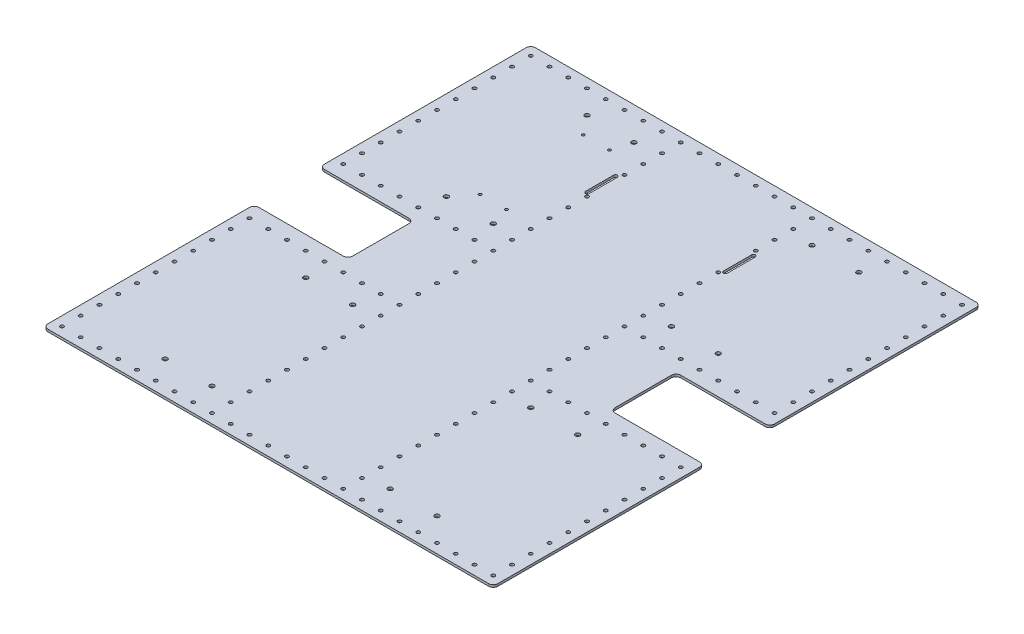
from build123d import *

# Parameters (mm, degrees)
BOSS_EXTRUDE1_DEPTH = 3.175
SKETCH2_R           = 2.4
CUT_EXTRUDE1_DEPTH  = 119.634
SKETCH3_R           = 2.425
CUT_EXTRUDE2_DEPTH  = 899.749353616
SKETCH3_3_R         = 2.425
CUT_EXTRUDE3_DEPTH  = 899.749353616
SKETCH4_R           = 3.100000023
SKETCH4_R_2         = 3.093357666
CUT_EXTRUDE4_DEPTH  = 899.749353616
FILLET1_R           = 6.35
SKETCH5_R           = 1.905
CUT_EXTRUDE5_DEPTH  = 899.749353616
CUT_EXTRUDE6_DEPTH  = 899.749353616
BOSS_EXTRUDE2_DEPTH = 3.175


with BuildPart() as part:
    # Sketch1 → Boss-Extrude1 (new body)
    with BuildSketch(Plane(origin=(0, 0, 0), x_dir=(1, 0, 0), z_dir=(0, 1, 0))):
        Polygon((609.6, 0), (0, 0), (0, -285.75), (127, -285.75), (127, -374.65), (0, -374.65), (0, -660.4), (609.6, -660.4), (609.6, -374.65), (482.6, -374.65), (482.6, -285.75), (609.6, -285.75), align=None)
    extrude(amount=BOSS_EXTRUDE1_DEPTH)

    # Sketch2 → Cut-Extrude1 (cut)
    with BuildSketch(Plane(origin=(0, 3.175, 0), x_dir=(1, 0, 0), z_dir=(0, 1, 0))):
        with Locations((12.7, -647.7)):
            Circle(SKETCH2_R)
        with Locations((38.1, -647.7)):
            Circle(SKETCH2_R)
        with Locations((63.5, -647.7)):
            Circle(SKETCH2_R)
        with Locations((88.9, -647.7)):
            Circle(SKETCH2_R)
        with Locations((114.3, -647.7)):
            Circle(SKETCH2_R)
        with Locations((139.7, -647.7)):
            Circle(SKETCH2_R)
        with Locations((165.1, -647.7)):
            Circle(SKETCH2_R)
        with Locations((190.5, -647.7)):
            Circle(SKETCH2_R)
        with Locations((215.9, -647.7)):
            Circle(SKETCH2_R)
        with Locations((241.3, -647.7)):
            Circle(SKETCH2_R)
        with Locations((266.7, -647.7)):
            Circle(SKETCH2_R)
        with Locations((292.1, -647.7)):
            Circle(SKETCH2_R)
        with Locations((317.5, -647.7)):
            Circle(SKETCH2_R)
        with Locations((342.9, -647.7)):
            Circle(SKETCH2_R)
        with Locations((368.3, -647.7)):
            Circle(SKETCH2_R)
        with Locations((393.7, -647.7)):
            Circle(SKETCH2_R)
        with Locations((419.1, -647.7)):
            Circle(SKETCH2_R)
        with Locations((444.5, -647.7)):
            Circle(SKETCH2_R)
        with Locations((469.9, -647.7)):
            Circle(SKETCH2_R)
        with Locations((495.3, -647.7)):
            Circle(SKETCH2_R)
        with Locations((520.7, -647.7)):
            Circle(SKETCH2_R)
        with Locations((546.1, -647.7)):
            Circle(SKETCH2_R)
        with Locations((571.5, -647.7)):
            Circle(SKETCH2_R)
        with Locations((596.9, -647.7)):
            Circle(SKETCH2_R)
        with Locations((12.7, -622.3)):
            Circle(SKETCH2_R)
        with Locations((12.7, -596.9)):
            Circle(SKETCH2_R)
        with Locations((12.7, -571.5)):
            Circle(SKETCH2_R)
        with Locations((12.7, -546.1)):
            Circle(SKETCH2_R)
        with Locations((12.7, -520.7)):
            Circle(SKETCH2_R)
        with Locations((12.7, -495.3)):
            Circle(SKETCH2_R)
        with Locations((12.7, -469.9)):
            Circle(SKETCH2_R)
        with Locations((12.7, -444.5)):
            Circle(SKETCH2_R)
        with Locations((12.7, -419.1)):
            Circle(SKETCH2_R)
        with Locations((12.7, -393.7)):
            Circle(SKETCH2_R)
        with Locations((596.9, -622.3)):
            Circle(SKETCH2_R)
        with Locations((596.9, -596.9)):
            Circle(SKETCH2_R)
        with Locations((596.9, -571.5)):
            Circle(SKETCH2_R)
        with Locations((596.9, -546.1)):
            Circle(SKETCH2_R)
        with Locations((596.9, -520.7)):
            Circle(SKETCH2_R)
        with Locations((596.9, -495.3)):
            Circle(SKETCH2_R)
        with Locations((596.9, -469.9)):
            Circle(SKETCH2_R)
        with Locations((596.9, -444.5)):
            Circle(SKETCH2_R)
        with Locations((596.9, -419.1)):
            Circle(SKETCH2_R)
        with Locations((596.9, -393.7)):
            Circle(SKETCH2_R)
        with Locations((215.9, -622.3)):
            Circle(SKETCH2_R)
        with Locations((393.7, -622.3)):
            Circle(SKETCH2_R)
        with Locations((215.9, -596.9)):
            Circle(SKETCH2_R)
        with Locations((393.7, -596.9)):
            Circle(SKETCH2_R)
        with Locations((215.9, -571.5)):
            Circle(SKETCH2_R)
        with Locations((393.7, -571.5)):
            Circle(SKETCH2_R)
        with Locations((215.9, -546.1)):
            Circle(SKETCH2_R)
        with Locations((393.7, -546.1)):
            Circle(SKETCH2_R)
        with Locations((215.9, -520.7)):
            Circle(SKETCH2_R)
        with Locations((393.7, -520.7)):
            Circle(SKETCH2_R)
        with Locations((215.9, -495.3)):
            Circle(SKETCH2_R)
        with Locations((393.7, -495.3)):
            Circle(SKETCH2_R)
        with Locations((215.9, -469.9)):
            Circle(SKETCH2_R)
        with Locations((393.7, -469.9)):
            Circle(SKETCH2_R)
        with Locations((215.9, -444.5)):
            Circle(SKETCH2_R)
        with Locations((393.7, -444.5)):
            Circle(SKETCH2_R)
        with Locations((215.9, -419.1)):
            Circle(SKETCH2_R)
        with Locations((393.7, -419.1)):
            Circle(SKETCH2_R)
        with Locations((215.9, -393.7)):
            Circle(SKETCH2_R)
        with Locations((393.7, -393.7)):
            Circle(SKETCH2_R)
        with Locations((215.9, -368.3)):
            Circle(SKETCH2_R)
        with Locations((393.7, -368.3)):
            Circle(SKETCH2_R)
        with Locations((215.9, -342.9)):
            Circle(SKETCH2_R)
        with Locations((393.7, -342.9)):
            Circle(SKETCH2_R)
        with Locations((215.9, -317.5)):
            Circle(SKETCH2_R)
        with Locations((393.7, -317.5)):
            Circle(SKETCH2_R)
        with Locations((215.9, -292.1)):
            Circle(SKETCH2_R)
        with Locations((393.7, -292.1)):
            Circle(SKETCH2_R)
        with Locations((215.9, -266.7)):
            Circle(SKETCH2_R)
        with Locations((393.7, -266.7)):
            Circle(SKETCH2_R)
        with Locations((215.9, -241.3)):
            Circle(SKETCH2_R)
        with Locations((393.7, -241.3)):
            Circle(SKETCH2_R)
        with Locations((215.9, -215.9)):
            Circle(SKETCH2_R)
        with Locations((393.7, -215.9)):
            Circle(SKETCH2_R)
        with Locations((215.9, -190.5)):
            Circle(SKETCH2_R)
        with Locations((393.7, -190.5)):
            Circle(SKETCH2_R)
        with Locations((215.9, -165.1)):
            Circle(SKETCH2_R)
        with Locations((393.7, -165.1)):
            Circle(SKETCH2_R)
        with Locations((215.9, -139.7)):
            Circle(SKETCH2_R)
        with Locations((393.7, -139.7)):
            Circle(SKETCH2_R)
        with Locations((215.9, -114.3)):
            Circle(SKETCH2_R)
        with Locations((393.7, -114.3)):
            Circle(SKETCH2_R)
        with Locations((215.9, -88.9)):
            Circle(SKETCH2_R)
        with Locations((393.7, -88.9)):
            Circle(SKETCH2_R)
        with Locations((215.9, -63.5)):
            Circle(SKETCH2_R)
        with Locations((393.7, -63.5)):
            Circle(SKETCH2_R)
        with Locations((215.9, -38.1)):
            Circle(SKETCH2_R)
        with Locations((393.7, -38.1)):
            Circle(SKETCH2_R)
        with Locations((215.9, -12.7)):
            Circle(SKETCH2_R)
        with Locations((393.7, -12.7)):
            Circle(SKETCH2_R)
        with Locations((12.7, -12.7)):
            Circle(SKETCH2_R)
        with Locations((38.1, -12.7)):
            Circle(SKETCH2_R)
        with Locations((63.5, -12.7)):
            Circle(SKETCH2_R)
        with Locations((88.9, -12.7)):
            Circle(SKETCH2_R)
        with Locations((114.3, -12.7)):
            Circle(SKETCH2_R)
        with Locations((139.7, -12.7)):
            Circle(SKETCH2_R)
        with Locations((165.1, -12.7)):
            Circle(SKETCH2_R)
        with Locations((190.5, -12.7)):
            Circle(SKETCH2_R)
        with Locations((241.3, -12.7)):
            Circle(SKETCH2_R)
        with Locations((266.7, -12.7)):
            Circle(SKETCH2_R)
        with Locations((292.1, -12.7)):
            Circle(SKETCH2_R)
        with Locations((317.5, -12.7)):
            Circle(SKETCH2_R)
        with Locations((342.9, -12.7)):
            Circle(SKETCH2_R)
        with Locations((368.3, -12.7)):
            Circle(SKETCH2_R)
        with Locations((419.1, -12.7)):
            Circle(SKETCH2_R)
        with Locations((444.5, -12.7)):
            Circle(SKETCH2_R)
        with Locations((469.9, -12.7)):
            Circle(SKETCH2_R)
        with Locations((495.3, -12.7)):
            Circle(SKETCH2_R)
        with Locations((520.7, -12.7)):
            Circle(SKETCH2_R)
        with Locations((546.1, -12.7)):
            Circle(SKETCH2_R)
        with Locations((571.5, -12.7)):
            Circle(SKETCH2_R)
        with Locations((596.9, -12.7)):
            Circle(SKETCH2_R)
        with Locations((12.7, -38.1)):
            Circle(SKETCH2_R)
        with Locations((12.7, -63.5)):
            Circle(SKETCH2_R)
        with Locations((12.7, -88.9)):
            Circle(SKETCH2_R)
        with Locations((12.7, -114.3)):
            Circle(SKETCH2_R)
        with Locations((12.7, -139.7)):
            Circle(SKETCH2_R)
        with Locations((12.7, -165.1)):
            Circle(SKETCH2_R)
        with Locations((12.7, -190.5)):
            Circle(SKETCH2_R)
        with Locations((12.7, -215.9)):
            Circle(SKETCH2_R)
        with Locations((12.7, -241.3)):
            Circle(SKETCH2_R)
        with Locations((12.7, -266.7)):
            Circle(SKETCH2_R)
        with Locations((596.9, -38.1)):
            Circle(SKETCH2_R)
        with Locations((596.9, -63.5)):
            Circle(SKETCH2_R)
        with Locations((596.9, -88.9)):
            Circle(SKETCH2_R)
        with Locations((596.9, -114.3)):
            Circle(SKETCH2_R)
        with Locations((596.9, -139.7)):
            Circle(SKETCH2_R)
        with Locations((596.9, -165.1)):
            Circle(SKETCH2_R)
        with Locations((596.9, -190.5)):
            Circle(SKETCH2_R)
        with Locations((596.9, -215.9)):
            Circle(SKETCH2_R)
        with Locations((596.9, -241.3)):
            Circle(SKETCH2_R)
        with Locations((596.9, -266.7)):
            Circle(SKETCH2_R)
    extrude(amount=-CUT_EXTRUDE1_DEPTH, mode=Mode.SUBTRACT)

    # Sketch3 → Cut-Extrude2 (cut, through all)
    with BuildSketch(Plane(origin=(0, 3.175, 0), x_dir=(1, 0, 0), z_dir=(0, 1, 0))):
        with Locations((571.5, -393.7)):
            Circle(SKETCH3_R)
        with Locations((38.1, -393.7)):
            Circle(SKETCH3_R)
        with Locations((63.5, -393.7)):
            Circle(SKETCH3_R)
        with Locations((88.9, -393.7)):
            Circle(SKETCH3_R)
        with Locations((114.3, -393.7)):
            Circle(SKETCH3_R)
        with Locations((139.7, -393.7)):
            Circle(SKETCH3_R)
        with Locations((165.1, -393.7)):
            Circle(SKETCH3_R)
        with Locations((190.5, -393.7)):
            Circle(SKETCH3_R)
        with Locations((419.1, -393.7)):
            Circle(SKETCH3_R)
        with Locations((444.5, -393.7)):
            Circle(SKETCH3_R)
        with Locations((469.9, -393.7)):
            Circle(SKETCH3_R)
        with Locations((495.3, -393.7)):
            Circle(SKETCH3_R)
        with Locations((520.7, -393.7)):
            Circle(SKETCH3_R)
        with Locations((546.1, -393.7)):
            Circle(SKETCH3_R)
    extrude(amount=-CUT_EXTRUDE2_DEPTH, mode=Mode.SUBTRACT)

    # Sketch3_3 → Cut-Extrude3 (cut, through all)
    with BuildSketch(Plane(origin=(0, 3.175, 0), x_dir=(1, 0, 0), z_dir=(0, 1, 0))):
        with Locations((63.5, -266.7)):
            Circle(SKETCH3_3_R)
        with Locations((38.1, -266.7)):
            Circle(SKETCH3_3_R)
        with Locations((88.9, -266.7)):
            Circle(SKETCH3_3_R)
        with Locations((114.3, -266.7)):
            Circle(SKETCH3_3_R)
        with Locations((139.7, -266.7)):
            Circle(SKETCH3_3_R)
        with Locations((165.1, -266.7)):
            Circle(SKETCH3_3_R)
        with Locations((190.5, -266.7)):
            Circle(SKETCH3_3_R)
        with Locations((419.1, -266.7)):
            Circle(SKETCH3_3_R)
        with Locations((444.5, -266.7)):
            Circle(SKETCH3_3_R)
        with Locations((469.9, -266.7)):
            Circle(SKETCH3_3_R)
        with Locations((495.3, -266.7)):
            Circle(SKETCH3_3_R)
        with Locations((520.7, -266.7)):
            Circle(SKETCH3_3_R)
        with Locations((571.5, -266.7)):
            Circle(SKETCH3_3_R)
        with Locations((546.1, -266.7)):
            Circle(SKETCH3_3_R)
    extrude(amount=-CUT_EXTRUDE3_DEPTH, mode=Mode.SUBTRACT)

    # Sketch4 → Cut-Extrude4 (cut, through all)
    with BuildSketch(Plane(origin=(0, 3.175, 0), x_dir=(1, 0, 0), z_dir=(0, 1, 0))):
        with Locations((425.45, -44.45)):
            Circle(SKETCH4_R)
        with Locations((488.95, -44.45)):
            Circle(SKETCH4_R)
        with Locations((425.45, -234.95)):
            Circle(SKETCH4_R)
        with Locations((488.95, -234.95)):
            Circle(SKETCH4_R_2)
        with Locations((120.65, -44.45)):
            Circle(SKETCH4_R)
        with Locations((120.65, -234.95)):
            Circle(SKETCH4_R_2)
        with Locations((184.15, -44.45)):
            Circle(SKETCH4_R)
        with Locations((184.15, -234.95)):
            Circle(SKETCH4_R)
        with Locations((120.65, -615.95)):
            Circle(SKETCH4_R)
        with Locations((184.15, -615.95)):
            Circle(SKETCH4_R)
        with Locations((120.65, -425.45)):
            Circle(SKETCH4_R_2)
        with Locations((184.15, -425.45)):
            Circle(SKETCH4_R)
        with Locations((488.95, -615.95)):
            Circle(SKETCH4_R)
        with Locations((488.95, -425.45)):
            Circle(SKETCH4_R_2)
        with Locations((425.45, -615.95)):
            Circle(SKETCH4_R)
        with Locations((425.45, -425.45)):
            Circle(SKETCH4_R)
    extrude(amount=-CUT_EXTRUDE4_DEPTH, mode=Mode.SUBTRACT)

    # Fillet1
    fillet1_edges = [part.edges().sort_by_distance(p)[0] for p in [
        (0, 1.5875, 285.75),
        (609.6, 1.5875, 0),
        (609.6, 1.5875, 285.75),
        (482.6, 1.5875, 285.75),
        (482.6, 1.5875, 374.65),
        (609.6, 1.5875, 374.65),
        (609.6, 1.5875, 660.4),
        (0, 1.5875, 660.4),
        (0, 1.5875, 374.65),
        (127, 1.5875, 374.65),
        (127, 1.5875, 285.75),
        (0, 1.5875, 0),
    ]]
    fillet(fillet1_edges, radius=FILLET1_R)

    # Sketch5 → Cut-Extrude5 (cut, through all)
    with BuildSketch(Plane(origin=(0, 3.175, 0), x_dir=(1, 0, 0), z_dir=(0, 1, 0))):
        with Locations((140.97, -69.85)):
            Circle(SKETCH5_R)
        with Locations((176.53, -69.85)):
            Circle(SKETCH5_R)
        with Locations((140.97, -209.55)):
            Circle(SKETCH5_R)
        with Locations((176.53, -209.55)):
            Circle(SKETCH5_R)
    extrude(amount=-CUT_EXTRUDE5_DEPTH, mode=Mode.SUBTRACT)

    # Sketch6 → Cut-Extrude6 (cut, through all)
    with BuildSketch(Plane(origin=(0, 3.175, 0), x_dir=(1, 0, 0), z_dir=(0, 1, 0))):
        with BuildLine():
            ThreePointArc((213.868, -96.52), (211.328, -93.98), (208.788, -96.52))
            Line((208.788, -96.52), (208.788, -134.62))
            ThreePointArc((208.788, -134.62), (211.328, -137.16), (213.868, -134.62))
            Line((213.868, -134.62), (213.868, -115.577096707))
            ThreePointArc((213.868, -115.577096707), (213.5, -114.3), (213.868, -113.022903293))
            Line((213.868, -113.022903293), (213.868, -96.52))
        make_face()
        with BuildLine():
            ThreePointArc((400.812, -96.52), (398.272, -93.98), (395.732, -96.52))
            Line((395.732, -96.52), (395.732, -113.022903293))
            ThreePointArc((395.732, -113.022903293), (396.1, -114.3), (395.732, -115.577096707))
            Line((395.732, -115.577096707), (395.732, -134.62))
            ThreePointArc((395.732, -134.62), (398.272, -137.16), (400.812, -134.62))
            Line((400.812, -134.62), (400.812, -96.52))
        make_face()
    extrude(amount=-CUT_EXTRUDE6_DEPTH, mode=Mode.SUBTRACT)

    # Sketch6_3 → Boss-Extrude2 (add)
    with BuildSketch(Plane(origin=(0, 3.175, 0), x_dir=(1, 0, 0), z_dir=(0, 1, 0))):
        with BuildLine():
            ThreePointArc((213.868, -115.577096707), (218.3, -114.3), (213.868, -113.022903293))
            Line((213.868, -113.022903293), (213.868, -115.577096707))
        make_face()
        with BuildLine():
            Line((395.732, -115.577096707), (395.732, -113.022903293))
            ThreePointArc((395.732, -113.022903293), (391.3, -114.3), (395.732, -115.577096707))
        make_face()
    extrude(amount=-BOSS_EXTRUDE2_DEPTH)


solid = part.part
